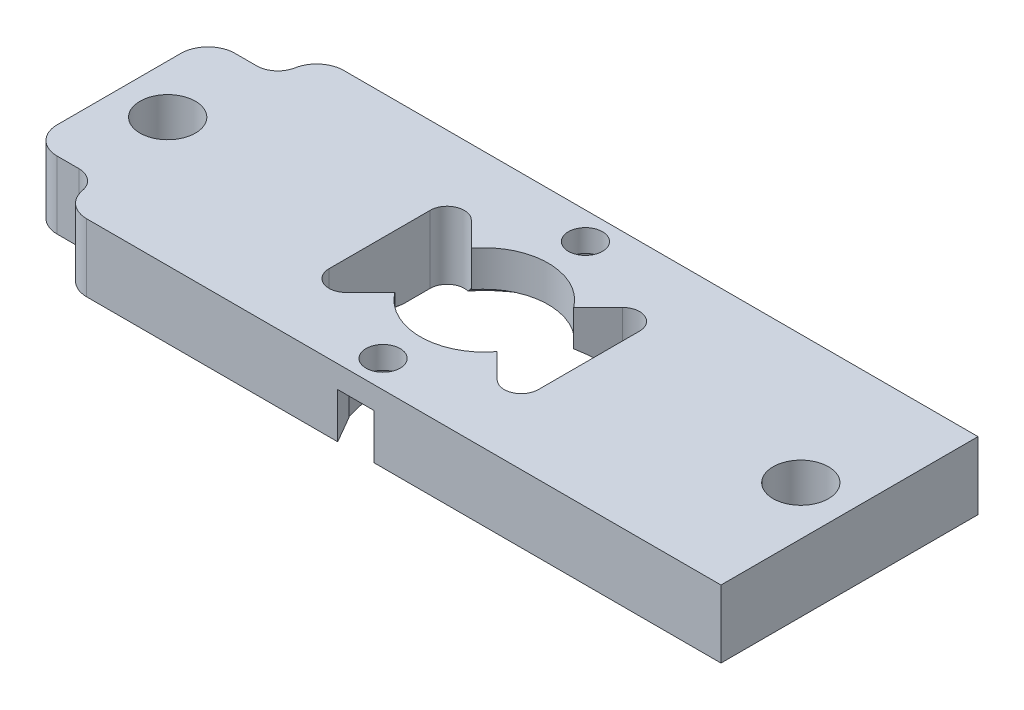
from build123d import *

# Parameters (mm, degrees)
SKETCH2_W           = 68.58
SKETCH2_H           = 24.13
SKETCH2_R           = 2.6
BOSS_EXTRUDE1_DEPTH = 6.35
CUT_EXTRUDE1_DEPTH  = 7.35
FILLET3_R           = 2.54
SKETCH4_R           = 6
CUT_EXTRUDE2_DEPTH  = 7.3500001
SKETCH9_R           = 1.6
CUT_EXTRUDE3_DEPTH  = 7.3500001
CUT_EXTRUDE4_DEPTH  = 4.25


with BuildPart() as part:
    # Sketch2 → Boss-Extrude1 (new body)
    with BuildSketch(Plane(origin=(0, 0, 0), x_dir=(1, 0, 0), z_dir=(0, 1, 0))):
        with Locations((34.29, 12.065)):
            Rectangle(SKETCH2_W, SKETCH2_H)
        with Locations((4.57, 12.065)):
            Circle(SKETCH2_R, mode=Mode.SUBTRACT)
        with Locations((64.01, 12.065)):
            Circle(SKETCH2_R, mode=Mode.SUBTRACT)
    extrude(amount=BOSS_EXTRUDE1_DEPTH)

    # Sketch3 → Cut-Extrude1 (cut, through all)
    with BuildSketch(Plane(origin=(0, 6.35, 0), x_dir=(1, 0, 0), z_dir=(0, 1, 0))):
        with BuildLine():
            Line((4.57, 3.715), (0, 3.715))
            Line((0, 3.715), (0, 0))
            Line((0, 0), (6.57, 0))
            Line((6.57, 0), (6.57, 1.715))
            ThreePointArc((6.57, 1.715), (5.984213562, 3.129213562), (4.57, 3.715))
        make_face()
        with BuildLine():
            ThreePointArc((4.57, 20.415), (5.984213562, 21.000786438), (6.57, 22.415))
            Line((6.57, 22.415), (6.57, 24.13))
            Line((6.57, 24.13), (0, 24.13))
            Line((0, 24.13), (0, 20.415))
            Line((0, 20.415), (4.57, 20.415))
        make_face()
    extrude(amount=-CUT_EXTRUDE1_DEPTH, mode=Mode.SUBTRACT)

    # Fillet3
    fillet3_edges = [part.edges().sort_by_distance(p)[0] for p in [
        (6.57, 3.175, 0),
        (0, 3.175, -3.715),
        (0, 3.175, -20.415),
        (6.57, 3.175, -24.13),
    ]]
    fillet(fillet3_edges, radius=FILLET3_R)

    # Sketch4 → Cut-Extrude2 (cut, through all)
    with BuildSketch(Plane(origin=(0, 6.35, 0), x_dir=(1, 0, 0), z_dir=(0, 1, 0))):
        with Locations((34.29, 12.065)):
            Circle(SKETCH4_R)
    extrude(amount=-CUT_EXTRUDE2_DEPTH, mode=Mode.SUBTRACT)

    # Sketch8 one side → Cut-Revolve6 (revolve, cut)
    with BuildSketch(Plane(origin=(34.29, 0, 0), x_dir=(0, 0, -1), z_dir=(1, 0, 0))):
        with BuildLine():
            Line((12.065, 0), (22.13, 0))
            ThreePointArc((22.13, 0), (17.5473974, 3.215969501), (12.065, 4.35))
            Line((12.065, 4.35), (12.065, 0))
        make_face()
    revolve(axis=Axis((34.29, 6.35, -12.065), (0, -1, 0)), mode=Mode.SUBTRACT)

    # Sketch9 → Cut-Extrude3 (cut, through all)
    with BuildSketch(Plane(origin=(0, 6.35, 0), x_dir=(1, 0, 0), z_dir=(0, 1, 0))):
        with Locations((34.29, 2.565)):
            Circle(SKETCH9_R)
        with Locations((34.29, 21.565)):
            Circle(SKETCH9_R)
        with BuildLine():
            Line((24.462758664, 7.315), (24.462758664, 16.815))
            ThreePointArc((24.462758664, 16.815), (25.450465172, 18.293207252), (27.194129514, 17.94637085))
            Line((27.194129514, 17.94637085), (29.483792257, 15.656708107))
            Line((29.483792257, 15.656708107), (29.483792257, 8.473291893))
            Line((29.483792257, 8.473291893), (27.194129514, 6.18362915))
            ThreePointArc((27.194129514, 6.18362915), (25.450465172, 5.836792748), (24.462758664, 7.315))
        make_face()
        with BuildLine():
            Line((44.117241336, 16.815), (44.117241336, 7.315))
            ThreePointArc((44.117241336, 7.315), (43.129534828, 5.836792748), (41.385870486, 6.18362915))
            Line((41.385870486, 6.18362915), (39.096207743, 8.473291893))
            Line((39.096207743, 8.473291893), (39.096207743, 15.656708107))
            Line((39.096207743, 15.656708107), (41.385870486, 17.94637085))
            ThreePointArc((41.385870486, 17.94637085), (43.129534828, 18.293207252), (44.117241336, 16.815))
        make_face()
    extrude(amount=-CUT_EXTRUDE3_DEPTH, mode=Mode.SUBTRACT)

    # Sketch10 → Cut-Extrude4 (cut)
    with BuildSketch(Plane.XZ):
        Polygon((31.114573519, -21.565), (32.70228676, -24.315), (35.87771324, -24.315), (37.465426481, -21.565), (35.87771324, -18.815), (32.70228676, -18.815), align=None)
        Polygon((32.70228676, -5.315), (35.87771324, -5.315), (37.465426481, -2.565), (35.87771324, 0.185), (32.70228676, 0.185), (31.114573519, -2.565), align=None)
    extrude(amount=-CUT_EXTRUDE4_DEPTH, mode=Mode.SUBTRACT)


solid = part.part
